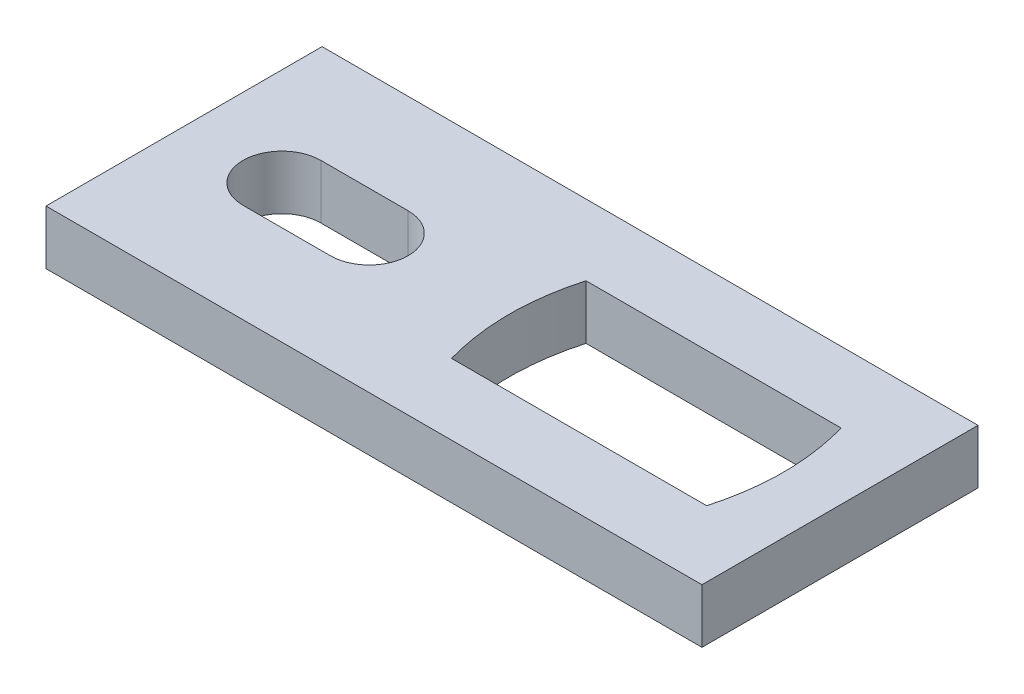
from build123d import *

# Parameters (mm, degrees)
SKETCH1_W           = 70.612
SKETCH1_H           = 29.718
BOSS_EXTRUDE1_DEPTH = 5.842
CUT_EXTRUDE1_DEPTH  = 6.842
CUT_EXTRUDE2_DEPTH  = 6.8420001


with BuildPart() as part:
    # Sketch1 → Boss-Extrude1 (new body)
    with BuildSketch(Plane(origin=(0, 0, 0), x_dir=(1, 0, 0), z_dir=(0, 1, 0))):
        Rectangle(SKETCH1_W, SKETCH1_H)
    extrude(amount=BOSS_EXTRUDE1_DEPTH)

    # Sketch2 → Cut-Extrude1 (cut, through all)
    with BuildSketch(Plane(origin=(0, 5.842, 0), x_dir=(1, 0, 0), z_dir=(0, 1, 0))):
        with BuildLine():
            Line((0.727778591, 7.239), (28.194, 7.239))
            add(Edge.make_bspline(
                [(28.194, -7.239), (30.226, 0), (28.194, 7.239)],
                knots=[0, 0, 0, 1, 1, 1], degree=2))
            Line((28.194, -7.239), (0.727778591, -7.239))
            add(Edge.make_bspline(
                [(0.727778591, -7.239), (-1.304221409, 0), (0.727778591, 7.239)],
                knots=[0, 0, 0, 1, 1, 1], degree=2))
        make_face()
    extrude(amount=-CUT_EXTRUDE1_DEPTH, mode=Mode.SUBTRACT)

    # Sketch3 → Cut-Extrude2 (cut, through all)
    with BuildSketch(Plane.XZ):
        with BuildLine():
            Line((-24.765, 4.191), (-15.367, 4.191))
            ThreePointArc((-15.367, 4.191), (-11.176, 0), (-15.367, -4.191))
            Line((-15.367, -4.191), (-24.765, -4.191))
            ThreePointArc((-24.765, -4.191), (-28.956, 0), (-24.765, 4.191))
        make_face()
    extrude(amount=-CUT_EXTRUDE2_DEPTH, mode=Mode.SUBTRACT)


solid = part.part
